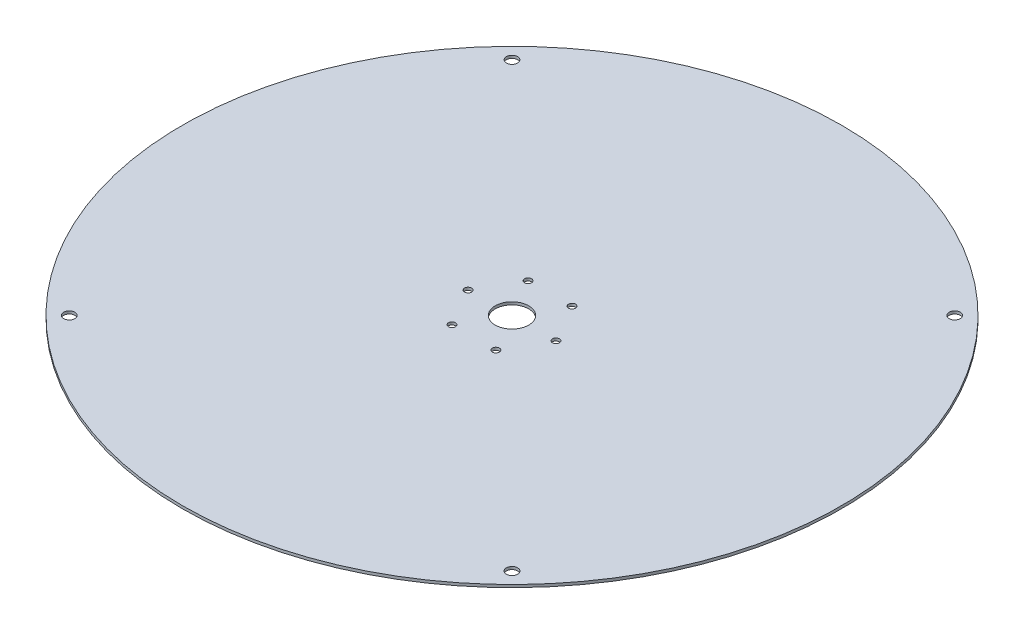
from build123d import *

# Parameters (mm, degrees)
CROQUIS1_R              = 375
SALIENTE_EXTRUIR1_DEPTH = 3.1
CROQUIS3_R              = 6.35
CROQUIS3_R_2            = 19.05
CORTAR_EXTRUIR2_DEPTH   = 4.1
CROQUIS4_R              = 4
CORTAR_EXTRUIR3_DEPTH   = 4.1


with BuildPart() as part:
    # Croquis1 → Saliente-Extruir1 (new body)
    with BuildSketch(Plane(origin=(0, 0, 0), x_dir=(1, 0, 0), z_dir=(0, 1, 0))):
        Circle(CROQUIS1_R)
    extrude(amount=SALIENTE_EXTRUIR1_DEPTH)

    # Croquis3 → Cortar-Extruir2 (cut, through all)
    with BuildSketch(Plane(origin=(0, 3.1, 0), x_dir=(1, 0, 0), z_dir=(0, 1, 0))):
        with Locations((-251.871435459, -251.871435459)):
            Circle(CROQUIS3_R)
        with Locations((-251.871435459, 251.871435459)):
            Circle(CROQUIS3_R)
        with Locations((251.871435459, 251.871435459)):
            Circle(CROQUIS3_R)
        with Locations((251.871435459, -251.871435459)):
            Circle(CROQUIS3_R)
        Circle(CROQUIS3_R_2)
    extrude(amount=-CORTAR_EXTRUIR2_DEPTH, mode=Mode.SUBTRACT)

    # Croquis4 → Cortar-Extruir3 (cut, through all)
    with BuildSketch(Plane(origin=(0, 3.1, 0), x_dir=(1, 0, 0), z_dir=(0, 1, 0))):
        with Locations((50, 0)):
            Circle(CROQUIS4_R)
        with Locations((25, -43.301270189)):
            Circle(CROQUIS4_R)
        with Locations((-25, -43.301270189)):
            Circle(CROQUIS4_R)
        with Locations((-50, 0)):
            Circle(CROQUIS4_R)
        with Locations((-25, 43.301270189)):
            Circle(CROQUIS4_R)
        with Locations((25, 43.301270189)):
            Circle(CROQUIS4_R)
    extrude(amount=-CORTAR_EXTRUIR3_DEPTH, mode=Mode.SUBTRACT)


solid = part.part
